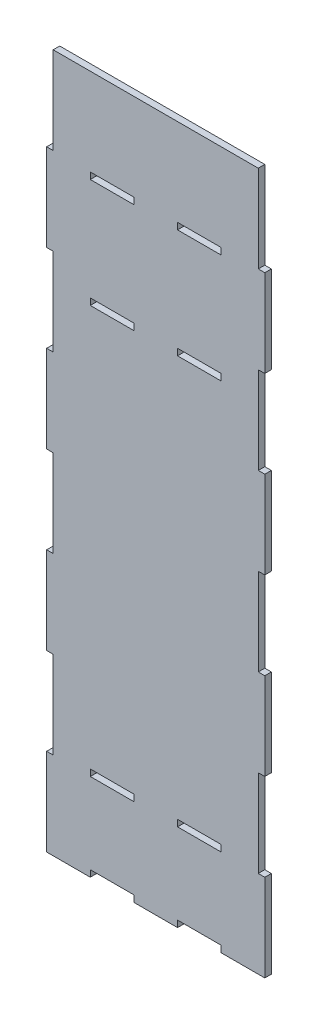
from build123d import *

# Parameters (mm, degrees)
SKETCH_1_W      = 20
SKETCH_1_H      = 3
EXTRUDE_1_DEPTH = 3


with BuildPart() as part:
    # 草图1 → 凸台-拉伸1 (new body)
    with BuildSketch(Plane.XY):
        Polygon((50, -53.716238765), (50, -13.716238765), (47, -13.716238765), (47, 26.283761235), (50, 26.283761235), (50, 66.283761235), (47, 66.283761235), (47, 106.283761235), (50, 106.283761235), (50, 146.283761235), (47, 146.283761235), (47, 186.283761235), (50, 186.283761235), (50, 226.283761235), (47, 226.283761235), (47, 266.283761235), (-47, 266.283761235), (-47, 226.283761235), (-50, 226.283761235), (-50, 186.283761235), (-47, 186.283761235), (-47, 146.283761235), (-50, 146.283761235), (-50, 106.283761235), (-47, 106.283761235), (-47, 66.283761235), (-50, 66.283761235), (-50, 26.283761235), (-47, 26.283761235), (-47, -13.716238765), (-50, -13.716238765), (-50, -53.716238765), (-30, -53.716238765), (-30, -50.716238765), (-10, -50.716238765), (-10, -53.716238765), (10, -53.716238765), (10, -50.716238765), (30, -50.716238765), (30, -53.716238765), align=None)
        with Locations((-20, -12.216238765)):
            Rectangle(SKETCH_1_W, SKETCH_1_H, mode=Mode.SUBTRACT)
        with Locations((20, -12.216238765)):
            Rectangle(SKETCH_1_W, SKETCH_1_H, mode=Mode.SUBTRACT)
        with Locations((-20, 174.783761235)):
            Rectangle(SKETCH_1_W, SKETCH_1_H, mode=Mode.SUBTRACT)
        with Locations((20, 174.783761235)):
            Rectangle(SKETCH_1_W, SKETCH_1_H, mode=Mode.SUBTRACT)
        with Locations((-20, 224.783761235)):
            Rectangle(SKETCH_1_W, SKETCH_1_H, mode=Mode.SUBTRACT)
        with Locations((20, 224.783761235)):
            Rectangle(SKETCH_1_W, SKETCH_1_H, mode=Mode.SUBTRACT)
    extrude(amount=EXTRUDE_1_DEPTH)


solid = part.part
